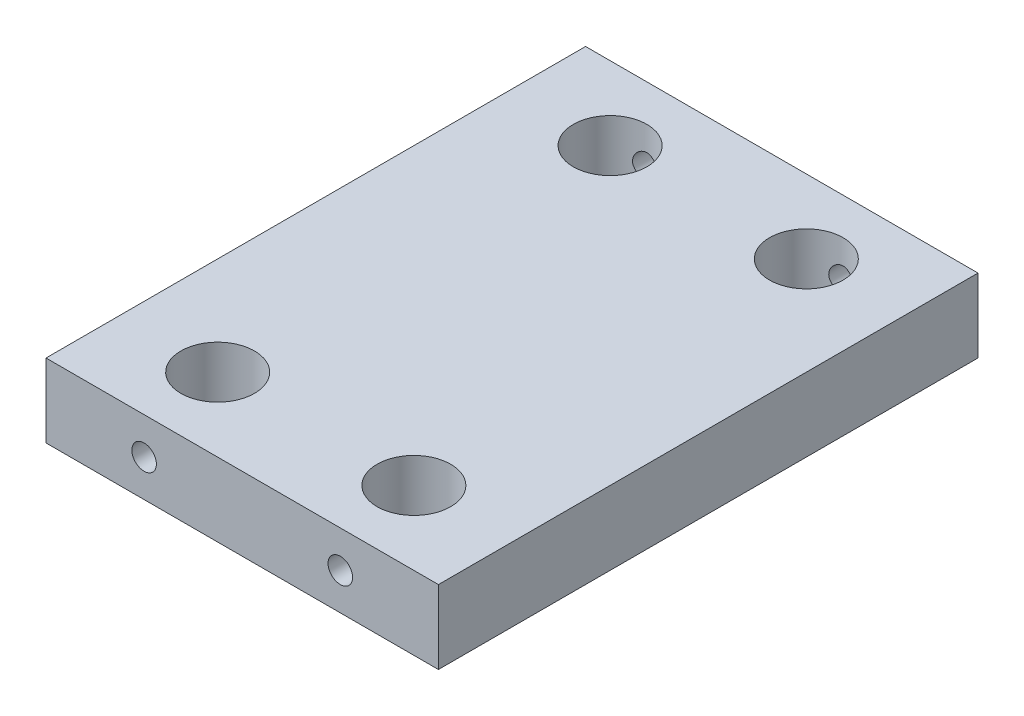
from build123d import *

# Parameters (mm, degrees)
SKETCH1_W           = 101.6
SKETCH1_H           = 139.7
BOSS_EXTRUDE1_DEPTH = 19.05


with BuildPart() as part:
    # Sketch1 → Boss-Extrude1 (new body)
    with BuildSketch(Plane(origin=(0, 0, 0), x_dir=(1, 0, 0), z_dir=(0, 1, 0))):
        Rectangle(SKETCH1_W, SKETCH1_H)
    extrude(amount=BOSS_EXTRUDE1_DEPTH)

    # Sketch2 → 3/4 (0.75) Diameter Hole1 (revolve, cut)
    with BuildSketch(Plane(origin=(-25.4, 19.05, -50.8), x_dir=(0, 0, 1), z_dir=(1, 0, 0))):
        Polygon((0, 0), (0, 24.773197396), (9.525, 19.05), (9.525, 0), align=None)
    f_3_4_0_75_diameter_hole1 = revolve(axis=Axis((-25.4, 25.4, -50.8), (0, -1, 0)), mode=Mode.SUBTRACT)

    # Mirror1: 3/4 (0.75) Diameter Hole1 across plane
    add(f_3_4_0_75_diameter_hole1.mirror(Plane.XY), mode=Mode.SUBTRACT)

    # Mirror4: 3/4 (0.75) Diameter Hole1 across plane
    add(f_3_4_0_75_diameter_hole1.mirror(Plane(origin=(0, 0, 0), x_dir=(0, 0, 1), z_dir=(1, 0, 0))), mode=Mode.SUBTRACT)

    # Mirror4 copy 1 sketch → Mirror4 copy 1 (revolve, cut)
    with BuildSketch(Plane(origin=(25.4, 19.05, 50.8), x_dir=(0, 0, -1), z_dir=(-1, 0, 0))):
        Polygon((0, 0), (0, 24.773197396), (9.525, 19.05), (9.525, 0), align=None)
    revolve(axis=Axis((25.4, 25.4, 50.8), (0, -1, 0)), mode=Mode.SUBTRACT)

    # Sketch4 → 1/4 (0.25) Diameter Hole1 (revolve, cut)
    with BuildSketch(Plane(origin=(25.4, 9.525, -69.85), x_dir=(0, 1, 0), z_dir=(1, 0, 0))):
        Polygon((0, 0), (0, 20.957732465), (3.175, 19.05), (3.175, 0), align=None)
    f_1_4_0_25_diameter_hole1 = revolve(axis=Axis((25.4, 9.525, -76.2), (0, 0, 1)), mode=Mode.SUBTRACT)

    # Mirror5: 1/4 (0.25) Diameter Hole1 across plane
    add(f_1_4_0_25_diameter_hole1.mirror(Plane.XY), mode=Mode.SUBTRACT)

    # Mirror10: 1/4 (0.25) Diameter Hole1 across plane
    add(f_1_4_0_25_diameter_hole1.mirror(Plane(origin=(0, 0, 0), x_dir=(0, 0, 1), z_dir=(1, 0, 0))), mode=Mode.SUBTRACT)

    # Mirror10 copy 1 sketch → Mirror10 copy 1 (revolve, cut)
    with BuildSketch(Plane(origin=(-25.4, 9.525, 69.85), x_dir=(0, 1, 0), z_dir=(-1, 0, 0))):
        Polygon((0, 0), (0, 20.957732465), (3.175, 19.05), (3.175, 0), align=None)
    revolve(axis=Axis((-25.4, 9.525, 76.2), (0, 0, -1)), mode=Mode.SUBTRACT)


solid = part.part
